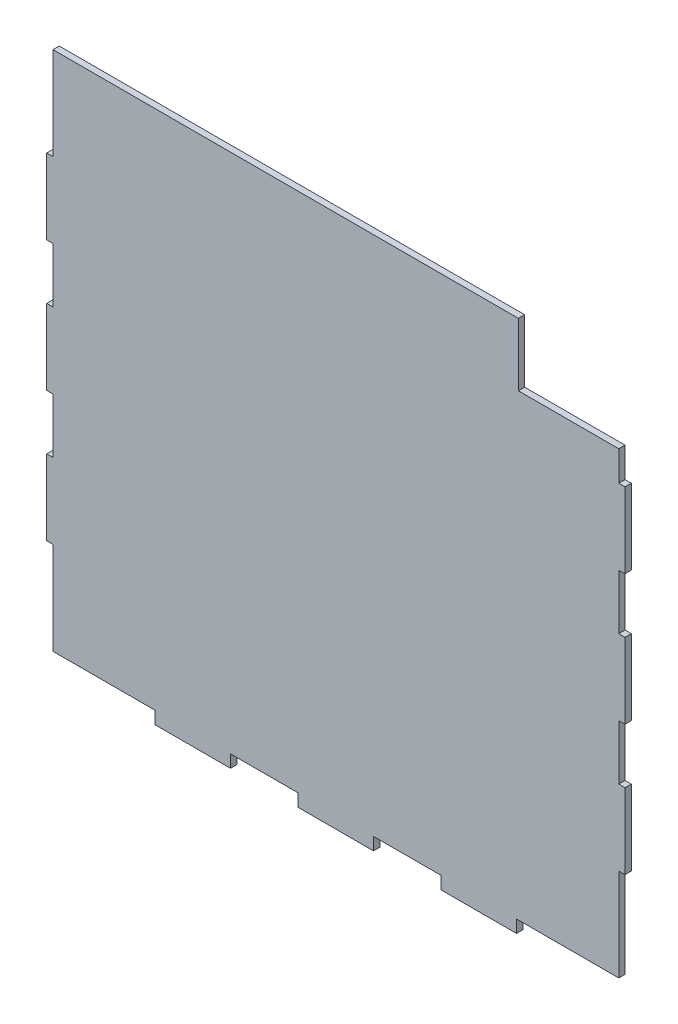
from build123d import *

# Parameters (mm, degrees)
SKETCH1_W           = 286.300000032
SKETCH1_H           = 263.675
BOSS_EXTRUDE1_DEPTH = 1.5875
SKETCH4_W           = 3.175
SKETCH4_H           = 38.1
SKETCH4_W_2         = 38.1
SKETCH4_H_2         = 6.35
BOSS_EXTRUDE2_DEPTH = 3.175
SKETCH3_W           = 50.8
SKETCH3_H           = 31.75
CUT_EXTRUDE2_DEPTH  = 3.175


with BuildPart() as part:
    # Sketch1 → Boss-Extrude1 (new body, symmetric)
    with BuildSketch(Plane.XY):
        with Locations((-144.737500016, 135.0125)):
            Rectangle(SKETCH1_W, SKETCH1_H)
    extrude(amount=BOSS_EXTRUDE1_DEPTH, both=True)

    # Sketch4 → Boss-Extrude2 (add)
    with BuildSketch(Plane.XY.offset(1.5875)):
        with Locations((-289.475000032, 200.93125)):
            Rectangle(SKETCH4_W, SKETCH4_H)
        with Locations((-289.475000032, 135.0125)):
            Rectangle(SKETCH4_W, SKETCH4_H)
        with Locations((-289.475000032, 69.09375)):
            Rectangle(SKETCH4_W, SKETCH4_H)
        with Locations((0, 200.93125)):
            Rectangle(SKETCH4_W, SKETCH4_H)
        with Locations((0, 135.0125)):
            Rectangle(SKETCH4_W, SKETCH4_H)
        with Locations((0, 69.09375)):
            Rectangle(SKETCH4_W, SKETCH4_H)
        with Locations((-217.106250024, 0)):
            Rectangle(SKETCH4_W_2, SKETCH4_H_2)
        with Locations((-144.737500016, 0)):
            Rectangle(SKETCH4_W_2, SKETCH4_H_2)
        with Locations((-72.368750008, 0)):
            Rectangle(SKETCH4_W_2, SKETCH4_H_2)
    extrude(amount=-BOSS_EXTRUDE2_DEPTH)

    # Sketch3 → Cut-Extrude2 (cut)
    with BuildSketch(Plane.XY.offset(1.5875)):
        with Locations((-26.9875, 250.975)):
            Rectangle(SKETCH3_W, SKETCH3_H)
    extrude(amount=-CUT_EXTRUDE2_DEPTH, mode=Mode.SUBTRACT)


solid = part.part
